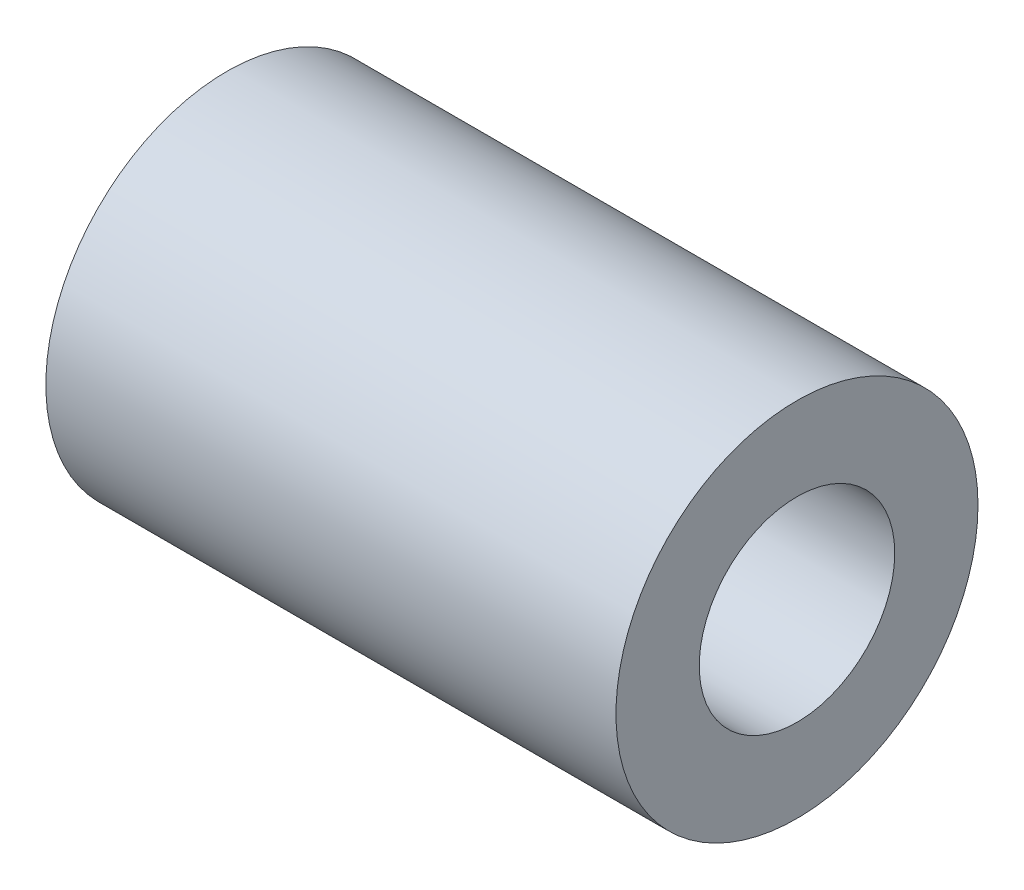
from build123d import *

# Parameters (mm, degrees)
ESQUISSE1_R        = 6.35
ESQUISSE1_R_2      = 3.429
BOSS_EXTRU_1_DEPTH = 20


with BuildPart() as part:
    # Esquisse1 → Boss.-Extru.1 (new body)
    with BuildSketch(Plane(origin=(0, 0, 0), x_dir=(0, 0, -1), z_dir=(1, 0, 0))):
        Circle(ESQUISSE1_R)
        Circle(ESQUISSE1_R_2, mode=Mode.SUBTRACT)
    extrude(amount=-BOSS_EXTRU_1_DEPTH)


solid = part.part
